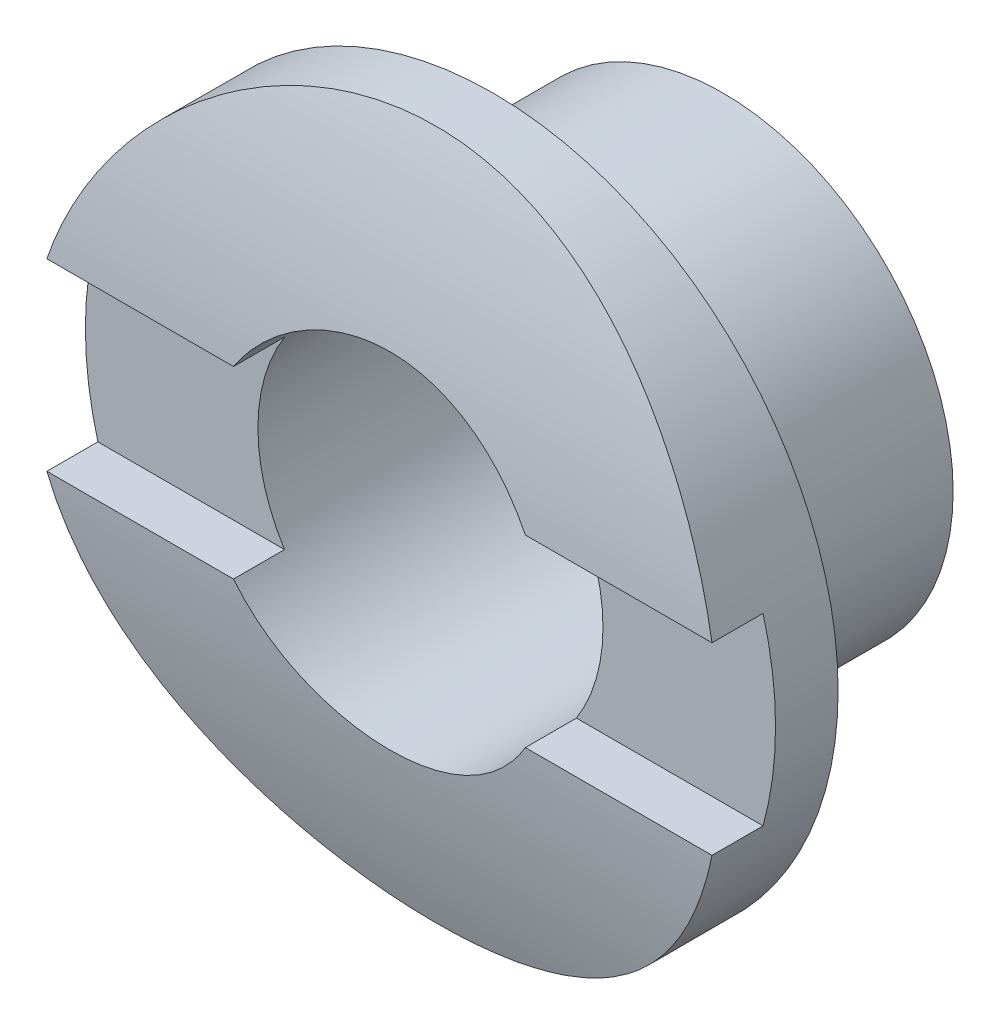
from build123d import *

# Parameters (mm, degrees)
SKETCH1_R               = 3.175
SKETCH1_R_2             = 2.38125
BOSS_EXTRUDE1_DEPTH     = 3.175
SKETCH2_R               = 4.7625
SKETCH2_R_2             = 2.38125
BOSS_EXTRUDE2_DEPTH     = 1.6256
SKETCH3_R               = 22.361166229
SKETCH3_R_2             = 13.97
CUT_EXTRUDE1_DEPTH      = 5.7625
CUT_EXTRUDE1_DEPTH_BACK = 5.7625
SKETCH4_W               = 0.762
SKETCH4_H               = 2.54
CUT_EXTRUDE2_DEPTH      = 5.7625001
CUT_EXTRUDE2_DEPTH_BACK = 5.7625001


with BuildPart() as part:
    # Sketch1 → Boss-Extrude1 (new body)
    with BuildSketch(Plane.XY):
        Circle(SKETCH1_R)
        Circle(SKETCH1_R_2, mode=Mode.SUBTRACT)
    extrude(amount=BOSS_EXTRUDE1_DEPTH)

    # Sketch2 → Boss-Extrude2 (add)
    with BuildSketch(Plane.XY.offset(3.175)):
        Circle(SKETCH2_R)
        Circle(SKETCH2_R_2, mode=Mode.SUBTRACT)
    extrude(amount=BOSS_EXTRUDE2_DEPTH)

    # Sketch3 → Cut-Extrude1 (cut, two sides)
    with BuildSketch(Plane(origin=(0, 0, 0), x_dir=(0, 0, -1), z_dir=(1, 0, 0))) as cut_extrude1_sk:
        with Locations((9.1694, 0)):
            Circle(SKETCH3_R)
        with Locations((9.1694, 0)):
            Circle(SKETCH3_R_2, mode=Mode.SUBTRACT)
    extrude(amount=CUT_EXTRUDE1_DEPTH, mode=Mode.SUBTRACT)
    extrude(cut_extrude1_sk.sketch, amount=-CUT_EXTRUDE1_DEPTH_BACK, mode=Mode.SUBTRACT)

    # Sketch4 → Cut-Extrude2 (cut, two sides)
    with BuildSketch(Plane(origin=(0, 0, 0), x_dir=(0, 0, -1), z_dir=(1, 0, 0))) as cut_extrude2_sk:
        with Locations((-4.4196, 0)):
            Rectangle(SKETCH4_W, SKETCH4_H)
    extrude(amount=CUT_EXTRUDE2_DEPTH, mode=Mode.SUBTRACT)
    extrude(cut_extrude2_sk.sketch, amount=-CUT_EXTRUDE2_DEPTH_BACK, mode=Mode.SUBTRACT)


solid = part.part
